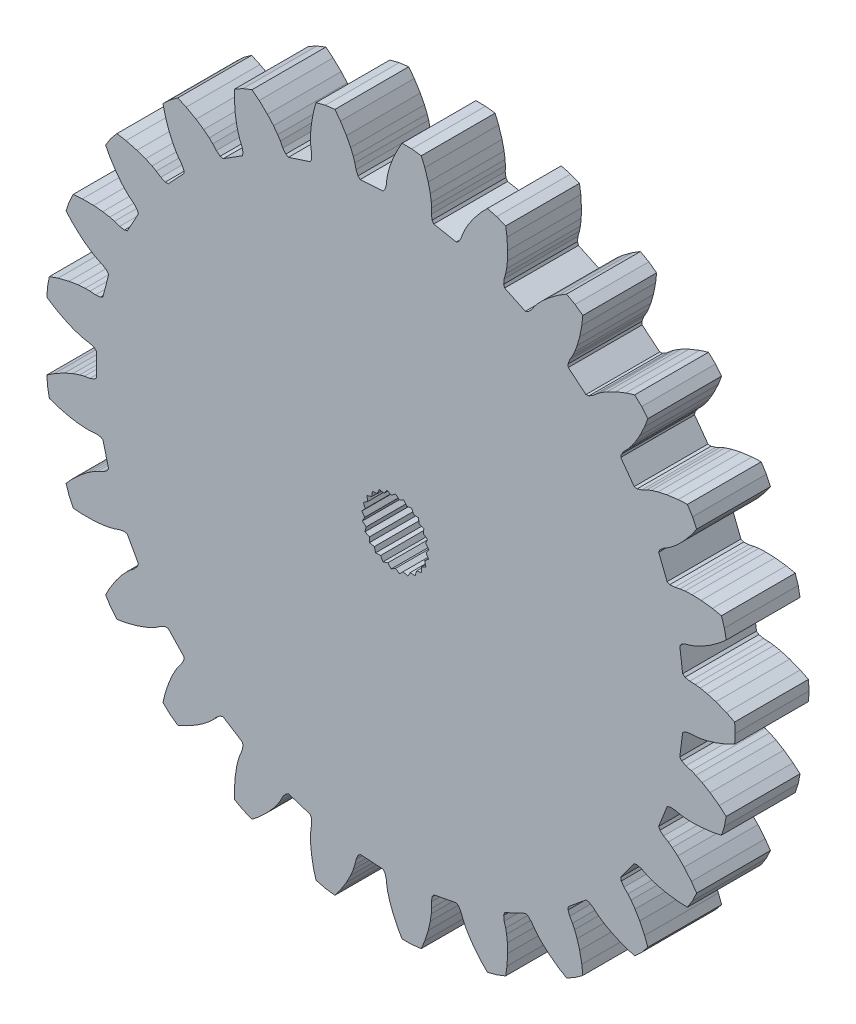
from build123d import *

# Parameters (mm, degrees)
BOSS_EXTRUDE1_DEPTH = 6.35


with BuildPart() as part:
    # Model → Boss-Extrude1 (new body)
    with BuildSketch(Plane.XY):
        Polygon((28.047622234, -8.531415237), (28.304165473, -7.741856334), (28.459727821, -6.926369945), (27.857816488, -6.412621108), (27.068053814, -5.845501019), (26.390426764, -5.440243152), (25.845384295, -5.173445181), (25.450194214, -5.019512229), (24.999291008, -4.886105071), (24.627377666, -4.699011826), (24.464696697, -4.497599406), (24.711586894, -2.543262258), (24.919246173, -2.388634693), (25.326003372, -2.299910413), (25.795917635, -2.282829553), (26.216973662, -2.232012465), (26.811242576, -2.109142993), (27.56836426, -1.885136042), (28.474352119, -1.532239063), (29.18511744, -1.184319852), (29.237245587, -0.355766685), (29.18511744, 0.472786483), (28.474352119, 0.820705693), (27.56836426, 1.173602672), (26.811242576, 1.397609623), (26.216973662, 1.520479095), (25.795917635, 1.571296184), (25.326003372, 1.588377043), (24.919246173, 1.677101323), (24.711586894, 1.831728889), (24.464696697, 3.786066037), (24.627377666, 3.987478456), (24.999291008, 4.174571701), (25.450194214, 4.307978859), (25.845384295, 4.461911811), (26.390426764, 4.728709782), (27.068053814, 5.133967649), (27.857816488, 5.701087739), (28.459727821, 6.214836575), (28.304165473, 7.030322964), (28.047622234, 7.819881867), (27.272662923, 7.980110408), (26.307376429, 8.096610461), (25.518332851, 8.125291316), (24.912177592, 8.096511948), (24.491712119, 8.041020149), (24.03231324, 7.940701457), (23.616270235, 7.925481898), (23.376680642, 8.023608792), (22.651523069, 9.855147749), (22.759003885, 10.090689539), (23.072704688, 10.364395993), (23.476264929, 10.605746987), (23.820757819, 10.853123629), (24.282326819, 11.247086201), (24.837881436, 11.808131141), (25.461795233, 12.553840101), (25.917032274, 13.201137834), (25.563553984, 13.952317436), (25.118715208, 14.653271185), (24.328255452, 14.615741308), (23.364322823, 14.488524309), (22.592935862, 14.320076943), (22.012981223, 14.141457049), (21.619525695, 13.983143116), (21.19950792, 13.771728265), (20.800320622, 13.653521168), (20.54385501, 13.688981716), (19.38599438, 15.282640155), (19.431521627, 15.537511358), (19.667298915, 15.880633037), (19.998159018, 16.214762897), (20.27030896, 16.540039645), (20.619402414, 17.036412701), (21.017977058, 17.717992198), (21.436839179, 18.595434391), (21.716797711, 19.335608924), (21.187613821, 19.975282361), (20.582430365, 20.543587454), (19.826137656, 20.3106573), (18.924126324, 19.94771676), (18.218865059, 19.592725342), (17.701551723, 19.275488266), (17.359828399, 19.024299646), (17.00558299, 18.715072607), (16.648333804, 18.50130536), (16.391106852, 18.471871446), (14.873295805, 19.727513944), (14.854008839, 19.985700066), (14.997047858, 20.376677374), (15.234418665, 20.782591492), (15.417125479, 21.165330011), (15.631808561, 21.732924606), (15.848359322, 22.492212513), (16.035851118, 23.44625502), (16.122940317, 24.232798464), (15.451301398, 24.720772703), (14.723799163, 25.120720441), (14.049194154, 24.707025867), (13.265780809, 24.131166675), (12.670959399, 23.611936621), (12.248792065, 23.176015536), (11.980272677, 22.847735333), (11.714058177, 22.46012598), (11.421194384, 22.164230364), (11.179368606, 22.071751429), (9.396976793, 22.910481351), (9.314087485, 23.155759608), (9.355400568, 23.570026002), (9.484367198, 24.0222193), (9.566150742, 24.438370722), (9.632934124, 25.041522801), (9.653854321, 25.830810266), (9.598194995, 26.801507087), (9.486942726, 27.584998026), (8.71505032, 27.890611849), (7.910940948, 28.097072045), (7.360411552, 27.528607003), (6.744820936, 26.77601251), (6.297814198, 26.125168954), (5.997319192, 25.597954385), (5.818875801, 25.213209652), (5.657419445, 24.771572905), (5.447342754, 24.412141131), (5.236112953, 24.262427966), (3.301134607, 24.631544826), (3.159851198, 24.848503483), (3.096842491, 25.260029083), (3.109301497, 25.730088594), (3.085023011, 26.153504594), (2.999710448, 26.754315892), (2.823685587, 27.524009082), (2.528372418, 28.450367766), (2.225769071, 29.181576582), (1.402124017, 29.285627149), (0.571932657, 29.285627149), (0.180070661, 28.598110389), (-0.229017404, 27.716068875), (-0.500122393, 26.974506711), (-0.660063864, 26.389125488), (-0.737219003, 25.972091151), (-0.783772318, 25.504176672), (-0.897862016, 25.10379316), (-1.065223494, 24.906252793), (-3.031206568, 24.782563623), (-3.222006723, 24.957570369), (-3.38537815, 25.340497507), (-3.490209614, 25.798887663), (-3.619024624, 26.202963457), (-3.85107263, 26.763682792), (-4.212982258, 27.465419052), (-4.729393658, 28.289233075), (-5.204334403, 28.922215229), (-6.027979456, 28.818164662), (-6.832088828, 28.611704466), (-7.040661293, 27.848335194), (-7.2175423, 26.892268571), (-7.295711016, 26.106582877), (-7.305049241, 25.499816655), (-7.276068188, 25.076696516), (-7.204793346, 24.611905092), (-7.215727376, 24.195727409), (-7.328704594, 23.96277203), (-9.202162448, 23.354048673), (-9.430490674, 23.476107192), (-9.683959594, 23.806375148), (-9.89949458, 24.224293609), (-10.124752193, 24.583639628), (-10.488955213, 25.069034942), (-11.014009496, 25.658721603), (-11.719071098, 26.328227701), (-12.336506967, 26.823210597), (-13.108399372, 26.517596773), (-13.835901607, 26.117649035), (-13.848079166, 25.32639255), (-13.781639031, 24.356374), (-13.661959846, 23.575932298), (-13.52010807, 22.985906431), (-13.38681181, 22.583286683), (-13.202187272, 22.150822869), (-13.109278609, 21.745000991), (-13.160772792, 21.491268042), (-14.82398918, 20.435758826), (-15.075498774, 20.497199731), (-15.403138803, 20.754056555), (-15.715834456, 21.105243968), (-16.023380908, 21.397281181), (-16.496854726, 21.776853301), (-17.152062572, 22.21743818), (-18.001472763, 22.690568822), (-18.722607989, 23.016450864), (-19.394246909, 22.528476626), (-19.999430365, 21.960171532), (-19.814447857, 21.190745389), (-19.508861257, 20.267724745), (-19.198854055, 19.541565057), (-18.914725348, 19.00535304), (-18.685489375, 18.648531764), (-18.399115779, 18.275568851), (-18.208202215, 17.905602059), (-18.194977796, 17.647034514), (-19.543446715, 16.211060966), (-19.802334404, 16.208023699), (-20.183558713, 16.375330132), (-20.573767216, 16.6377201), (-20.944278232, 16.844098734), (-21.497272746, 17.093997747), (-22.241465038, 17.357797277), (-23.181852252, 17.604823926), (-23.961375257, 17.741128745), (-24.490559146, 17.101455308), (-24.935397922, 16.400501559), (-24.564878479, 15.701251632), (-24.039346544, 14.883225676), (-23.558490217, 14.256975286), (-23.14993743, 13.808269291), (-22.839165484, 13.51966688), (-22.469036737, 13.229639501), (-22.192114073, 12.918774168), (-22.11500199, 12.671618777), (-23.063994178, 10.945408395), (-23.313993097, 10.8780838), (-23.724847961, 10.945327363), (-24.168051078, 11.102432959), (-24.578246088, 11.210185486), (-25.176014621, 11.314709319), (-25.962431018, 11.385148004), (-26.934707268, 11.390549066), (-27.723637755, 11.328712131), (-28.077116044, 10.57753253), (-28.333659283, 9.787973627), (-27.800884004, 9.20283636), (-27.088427839, 8.541204672), (-26.466936359, 8.054213195), (-25.959630365, 7.721207071), (-25.586849391, 7.518957475), (-25.156222042, 7.330089115), (-24.810690349, 7.097858055), (-24.674535837, 6.877644501), (-25.164422626, 4.969661432), (-25.389824423, 4.842279759), (-25.80449432, 4.805235292), (-26.272843969, 4.847184994), (-26.696948912, 4.849540927), (-27.301931467, 4.802121962), (-28.081158536, 4.674773882), (-29.024232129, 4.438209989), (-29.772998694, 4.182116741), (-29.928561042, 3.366630352), (-29.980689189, 2.538077185), (-29.319134304, 2.103818905), (-28.46452015, 1.640154236), (-27.741444112, 1.323021138), (-27.167260814, 1.126638884), (-26.75589401, 1.02345019), (-26.29182596, 0.947608144), (-25.899396264, 0.808603287), (-25.712754413, 0.629168396), (-25.712754413, -1.340701766), (-25.899396264, -1.520136656), (-26.29182596, -1.659141513), (-26.75589401, -1.73498356), (-27.167260814, -1.838172254), (-27.741444112, -2.034554508), (-28.46452015, -2.351687606), (-29.319134304, -2.815352275), (-29.980689189, -3.249610554), (-29.928561042, -4.078163722), (-29.772998694, -4.893650111), (-29.024232129, -5.149743358), (-28.081158536, -5.386307251), (-27.301931467, -5.513655332), (-26.696948912, -5.561074296), (-26.272843969, -5.558718364), (-25.80449432, -5.516768662), (-25.389824423, -5.553813129), (-25.164422626, -5.681194801), (-24.674535837, -7.58917787), (-24.810690349, -7.809391424), (-25.156222042, -8.041622485), (-25.586849391, -8.230490845), (-25.959630365, -8.43274044), (-26.466936359, -8.765746564), (-27.088427839, -9.252738041), (-27.800884004, -9.91436973), (-28.333659283, -10.499506997), (-28.077116044, -11.2890659), (-27.723637755, -12.040245501), (-26.934707268, -12.102082436), (-25.962431018, -12.096681374), (-25.176014621, -12.026242688), (-24.578246088, -11.921718856), (-24.168051078, -11.813966329), (-23.724847961, -11.656860732), (-23.313993097, -11.589617169), (-23.063994178, -11.656941765), (-22.11500199, -13.383152147), (-22.192114073, -13.630307538), (-22.469036737, -13.94117287), (-22.839165484, -14.23120025), (-23.14993743, -14.519802661), (-23.558490217, -14.968508656), (-24.039346544, -15.594759046), (-24.564878479, -16.412785001), (-24.935397922, -17.112034929), (-24.490559146, -17.812988678), (-23.961375257, -18.452662115), (-23.181852252, -18.316357295), (-22.241465038, -18.069330647), (-21.497272746, -17.805531117), (-20.944278232, -17.555632104), (-20.573767216, -17.349253469), (-20.183558713, -17.086863501), (-19.802334404, -16.919557069), (-19.543446715, -16.922594335), (-18.194977796, -18.358567884), (-18.208202215, -18.617135429), (-18.399115779, -18.987102221), (-18.685489375, -19.360065134), (-18.914725348, -19.716886409), (-19.198854055, -20.253098427), (-19.508861257, -20.979258115), (-19.814447857, -21.902278758), (-19.999430365, -22.671704902), (-19.394246909, -23.240009995), (-18.722607989, -23.727984234), (-18.001472763, -23.402102192), (-17.152062572, -22.928971549), (-16.496854726, -22.48838667), (-16.023380908, -22.108814551), (-15.715834456, -21.816777338), (-15.403138803, -21.465589925), (-15.075498774, -21.208733101), (-14.82398918, -21.147292196), (-13.160772792, -22.202801412), (-13.109278609, -22.456534361), (-13.202187272, -22.862356239), (-13.38681181, -23.294820053), (-13.52010807, -23.6974398), (-13.661959846, -24.287465667), (-13.781639031, -25.06790737), (-13.848079166, -26.037925919), (-13.835901607, -26.829182405), (-13.108399372, -27.229130143), (-12.336506967, -27.534743966), (-11.719071098, -27.039761071), (-11.014009496, -26.370254972), (-10.488955213, -25.780568312), (-10.124752193, -25.295172998), (-9.89949458, -24.935826979), (-9.683959594, -24.517908518), (-9.430490674, -24.187640561), (-9.202162448, -24.065582043), (-7.328704594, -24.6743054), (-7.215727376, -24.907260779), (-7.204793346, -25.323438462), (-7.276068188, -25.788229885), (-7.305049241, -26.211350025), (-7.295711016, -26.818116246), (-7.2175423, -27.60380194), (-7.040661293, -28.559868563), (-6.832088828, -29.323237836), (-6.027979456, -29.529698032), (-5.204334403, -29.633748599), (-4.729393658, -29.000766445), (-4.212982258, -28.176952422), (-3.85107263, -27.475216161), (-3.619024624, -26.914496826), (-3.490209614, -26.510421033), (-3.38537815, -26.052030877), (-3.222006723, -25.669103738), (-3.031206568, -25.494096992), (-1.065223494, -25.617786163), (-0.897862016, -25.815326529), (-0.783772318, -26.215710042), (-0.737219003, -26.683624521), (-0.660063864, -27.100658858), (-0.500122393, -27.686040081), (-0.229017404, -28.427602245), (0.180070661, -29.309643759), (0.571932657, -29.997160519), (1.402124017, -29.997160519), (2.225769071, -29.893109952), (2.528372418, -29.161901135), (2.823685587, -28.235542452), (2.999710448, -27.465849262), (3.085023011, -26.865037963), (3.109301497, -26.441621964), (3.096842491, -25.971562453), (3.159851198, -25.560036853), (3.301134607, -25.343078196), (5.236112953, -24.973961335), (5.447342754, -25.123674501), (5.657419445, -25.483106275), (5.818875801, -25.924743021), (5.997319192, -26.309487755), (6.297814198, -26.836702324), (6.744820936, -27.48754588), (7.360411552, -28.240140373), (7.910940948, -28.808605415), (8.71505032, -28.602145219), (9.486942726, -28.296531396), (9.598194995, -27.513040457), (9.653854321, -26.542343636), (9.632934124, -25.75305617), (9.566150742, -25.149904092), (9.484367198, -24.73375267), (9.355400568, -24.281559372), (9.314087485, -23.867292977), (9.396976793, -23.622014721), (11.179368606, -22.783284798), (11.421194384, -22.875763734), (11.714058177, -23.17165935), (11.980272677, -23.559268702), (12.248792065, -23.887548906), (12.670959399, -24.32346999), (13.265780809, -24.842700044), (14.049194154, -25.418559237), (14.723799163, -25.83225381), (15.451301398, -25.432306072), (16.122940317, -24.944331834), (16.035851118, -24.157788389), (15.848359322, -23.203745883), (15.631808561, -22.444457976), (15.417125479, -21.87686338), (15.234418665, -21.494124861), (14.997047858, -21.088210744), (14.854008839, -20.697233436), (14.873295805, -20.439047314), (16.391106852, -19.183404816), (16.648333804, -19.21283873), (17.00558299, -19.426605977), (17.359828399, -19.735833015), (17.701551723, -19.987021636), (18.218865059, -20.304258711), (18.924126324, -20.659250129), (19.826137656, -21.02219067), (20.582430365, -21.255120824), (21.187613821, -20.686815731), (21.716797711, -20.047142294), (21.436839179, -19.306967761), (21.017977058, -18.429525568), (20.619402414, -17.74794607), (20.27030896, -17.251573015), (19.998159018, -16.926296267), (19.667298915, -16.592166407), (19.431521627, -16.249044728), (19.38599438, -15.994173524), (20.54385501, -14.400515086), (20.800320622, -14.365054538), (21.19950792, -14.483261634), (21.619525695, -14.694676486), (22.012981223, -14.852990419), (22.592935862, -15.031610313), (23.364322823, -15.200057678), (24.328255452, -15.327274678), (25.118715208, -15.364804555), (25.563553984, -14.663850806), (25.917032274, -13.912671204), (25.461795233, -13.265373471), (24.837881436, -12.519664511), (24.282326819, -11.958619571), (23.820757819, -11.564656999), (23.476264929, -11.317280357), (23.072704688, -11.075929362), (22.759003885, -10.802222909), (22.651523069, -10.566681119), (23.376680642, -8.735142161), (23.616270235, -8.637015268), (24.03231324, -8.652234826), (24.491712119, -8.752553518), (24.912177592, -8.808045318), (25.518332851, -8.836824686), (26.307376429, -8.808143831), (27.272662923, -8.691643778), align=None)
        Polygon((0.000786793, 2.869770476), (-0.331346276, 2.603874435), (-0.719170431, 2.778818728), (-0.974743272, 2.438678164), (-1.393890094, 2.511678315), (-1.556844126, 2.118665511), (-1.980977079, 2.085134652), (-2.041073301, 1.663944049), (-2.443542552, 1.525989048), (-2.397004896, 1.103085599), (-2.752521822, 0.869374675), (-2.602274422, 0.47133096), (-2.888500586, 0.15654903), (-2.643984038, -0.191624401), (-2.842934798, -0.56769843), (-2.519512976, -0.844124559), (-2.618687524, -1.257860573), (-2.23668221, -1.445170531), (-2.229849045, -1.870571974), (-1.813263038, -1.956996387), (-1.700851513, -2.367333723), (-1.275860444, -2.347442226), (-1.064933787, -2.716932451), (-0.658241408, -2.591974901), (-0.362052919, -2.897401584), (0.000786793, -2.675229524), (0.363626504, -2.897401584), (0.659814994, -2.591974901), (1.066507373, -2.716932451), (1.277434029, -2.347442226), (1.702425098, -2.367333723), (1.814836623, -1.956996387), (2.23142263, -1.870571974), (2.238255795, -1.445170531), (2.620261109, -1.257860573), (2.521086561, -0.844124559), (2.844508383, -0.56769843), (2.645557623, -0.191624401), (2.890074171, 0.15654903), (2.603848007, 0.47133096), (2.754095407, 0.869374675), (2.398578482, 1.103085599), (2.445116137, 1.525989048), (2.042646886, 1.663944049), (1.982550664, 2.085134652), (1.558417711, 2.118665511), (1.395463679, 2.511678315), (0.976316857, 2.438678164), (0.720744016, 2.778818728), (0.332919862, 2.603874435), align=None, mode=Mode.SUBTRACT)
    extrude(amount=BOSS_EXTRUDE1_DEPTH)


solid = part.part
